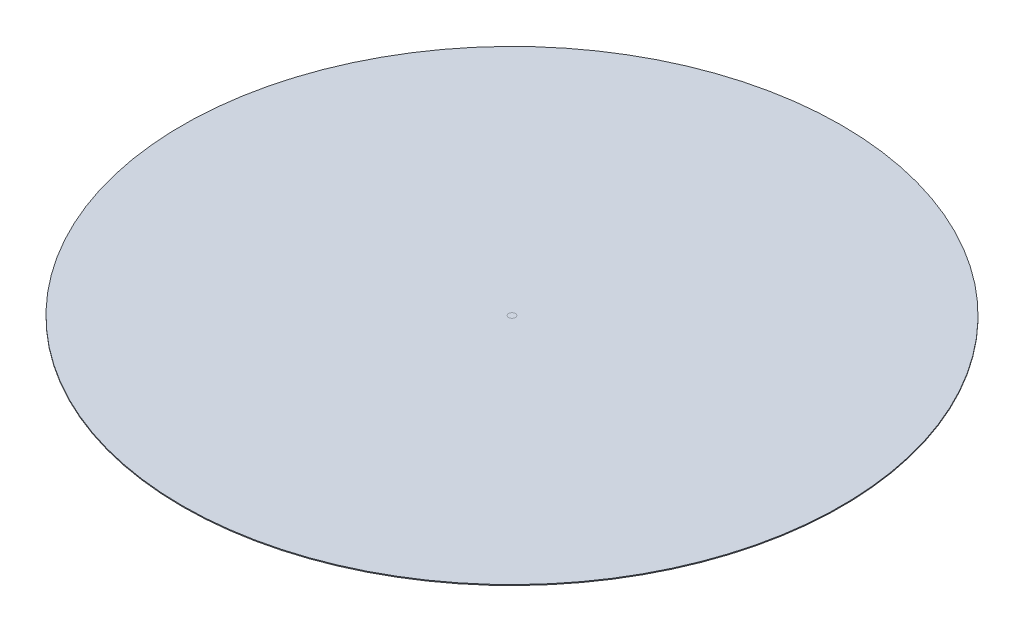
from build123d import *

# Parameters (mm, degrees)
SKETCH1_R           = 9.525
BOSS_EXTRUDE1_DEPTH = 0.0254


with BuildPart() as part:
    # Sketch1 → Boss-Extrude1 (new body)
    with BuildSketch(Plane(origin=(0, 0, 0), x_dir=(1, 0, 0), z_dir=(0, 1, 0))):
        Circle(SKETCH1_R)
    extrude(amount=BOSS_EXTRUDE1_DEPTH)


solid = part.part
